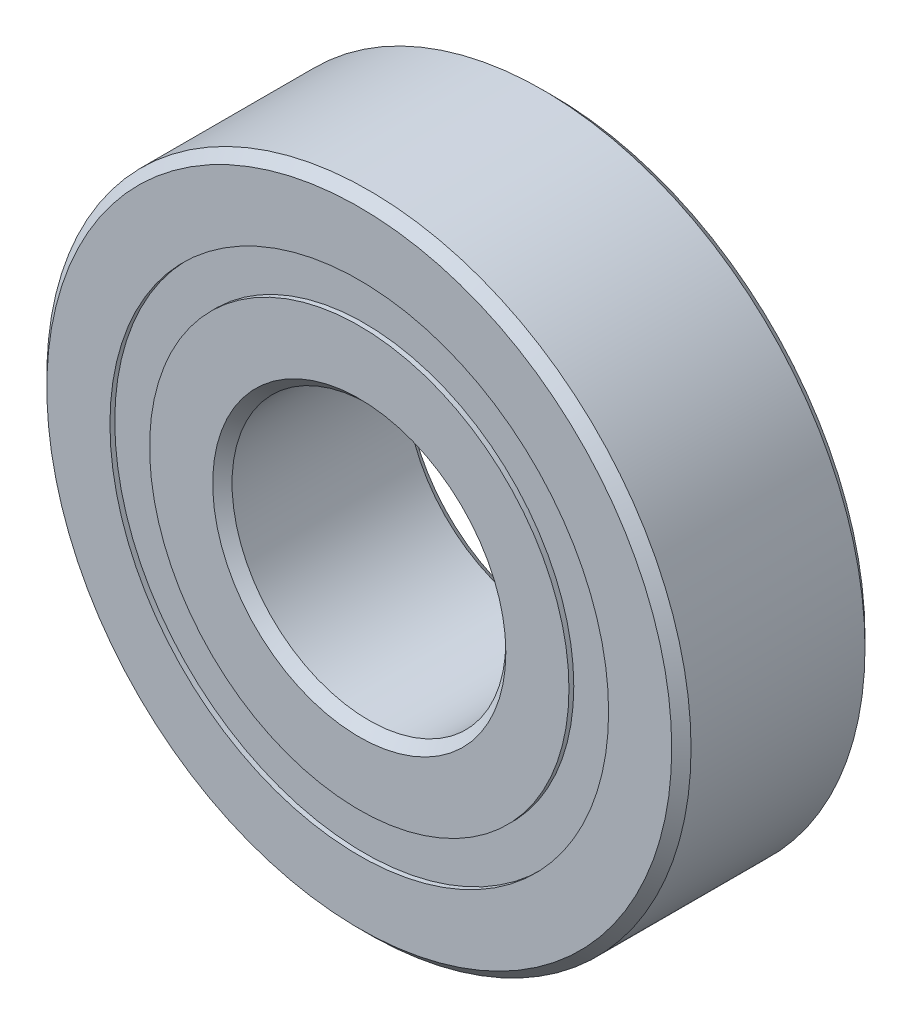
from build123d import *

# Parameters (mm, degrees)
CIRPATTERN1_COUNT = 14
SKETCH6_W         = 2.763011064
SKETCH6_H         = 2.461538462


with BuildPart() as part:
    # Sketch1 → Revolve1 (revolve)
    with BuildSketch(Plane(origin=(0, 0, 0), x_dir=(0, 0, -1), z_dir=(1, 0, 0))):
        with BuildLine():
            Line((5.4, 20), (-5.4, 20))
            Line((-5.4, 20), (-6, 19.4))
            Line((-6, 19.4), (-6, 15.480769231))
            Line((-6, 15.480769231), (-2.666666667, 15.480769231))
            ThreePointArc((-2.666666667, 15.480769231), (0, 17.186988936), (2.666666667, 15.480769231))
            Line((2.666666667, 15.480769231), (6, 15.480769231))
            Line((6, 15.480769231), (6, 19.4))
            Line((6, 19.4), (5.4, 20))
        make_face()
    revolve(axis=Axis((0, 0, 6), (0, 0, -1)))


with BuildPart() as body_2:
    # Sketch3 → Revolve3 (revolve)
    with BuildSketch(Plane(origin=(0, 0, 0), x_dir=(0, 0, -1), z_dir=(1, 0, 0))):
        with BuildLine():
            Line((-6, 13.019230769), (-2.666666667, 13.019230769))
            ThreePointArc((-2.666666667, 13.019230769), (0, 11.313011064), (2.666666667, 13.019230769))
            Line((2.666666667, 13.019230769), (6, 13.019230769))
            Line((6, 13.019230769), (6, 9.1))
            Line((6, 9.1), (5.4, 8.5))
            Line((5.4, 8.5), (-5.4, 8.5))
            Line((-5.4, 8.5), (-6, 9.1))
            Line((-6, 9.1), (-6, 13.019230769))
        make_face()
    revolve(axis=Axis((0, 0, 6), (0, 0, -1)))


with BuildPart() as body_3:
    # Sketch4 → Revolve4 (revolve)
    with BuildSketch(Plane(origin=(0, 0, 0), x_dir=(0, 0, -1), z_dir=(1, 0, 0))):
        with BuildLine():
            Line((-2.936988936, 14.25), (2.936988936, 14.25))
            ThreePointArc((2.936988936, 14.25), (0, 17.186988936), (-2.936988936, 14.25))
        make_face()
    revolve(axis=Axis((0, 14.25, 2.936988936), (0, 0, -1)))


with BuildPart() as cirpattern1_1:
    # CirPattern1: pattern copy
    add(body_3.part.rotate(Axis((0, 0, -6), (0, 0, 1)), 1 * 360 / CIRPATTERN1_COUNT))


with BuildPart() as cirpattern1_2:
    # CirPattern1: pattern copy
    add(body_3.part.rotate(Axis((0, 0, -6), (0, 0, 1)), 2 * 360 / CIRPATTERN1_COUNT))


with BuildPart() as cirpattern1_3:
    # CirPattern1: pattern copy
    add(body_3.part.rotate(Axis((0, 0, -6), (0, 0, 1)), 3 * 360 / CIRPATTERN1_COUNT))


with BuildPart() as cirpattern1_4:
    # CirPattern1: pattern copy
    add(body_3.part.rotate(Axis((0, 0, -6), (0, 0, 1)), 4 * 360 / CIRPATTERN1_COUNT))


with BuildPart() as cirpattern1_5:
    # CirPattern1: pattern copy
    add(body_3.part.rotate(Axis((0, 0, -6), (0, 0, 1)), 5 * 360 / CIRPATTERN1_COUNT))


with BuildPart() as cirpattern1_6:
    # CirPattern1: pattern copy
    add(body_3.part.rotate(Axis((0, 0, -6), (0, 0, 1)), 6 * 360 / CIRPATTERN1_COUNT))


with BuildPart() as cirpattern1_7:
    # CirPattern1: pattern copy
    add(body_3.part.rotate(Axis((0, 0, -6), (0, 0, 1)), 7 * 360 / CIRPATTERN1_COUNT))


with BuildPart() as cirpattern1_8:
    # CirPattern1: pattern copy
    add(body_3.part.rotate(Axis((0, 0, -6), (0, 0, 1)), 8 * 360 / CIRPATTERN1_COUNT))


with BuildPart() as cirpattern1_9:
    # CirPattern1: pattern copy
    add(body_3.part.rotate(Axis((0, 0, -6), (0, 0, 1)), 9 * 360 / CIRPATTERN1_COUNT))


with BuildPart() as cirpattern1_10:
    # CirPattern1: pattern copy
    add(body_3.part.rotate(Axis((0, 0, -6), (0, 0, 1)), 10 * 360 / CIRPATTERN1_COUNT))


with BuildPart() as cirpattern1_11:
    # CirPattern1: pattern copy
    add(body_3.part.rotate(Axis((0, 0, -6), (0, 0, 1)), 11 * 360 / CIRPATTERN1_COUNT))


with BuildPart() as cirpattern1_12:
    # CirPattern1: pattern copy
    add(body_3.part.rotate(Axis((0, 0, -6), (0, 0, 1)), 12 * 360 / CIRPATTERN1_COUNT))


with BuildPart() as cirpattern1_13:
    # CirPattern1: pattern copy
    add(body_3.part.rotate(Axis((0, 0, -6), (0, 0, 1)), 13 * 360 / CIRPATTERN1_COUNT))


with BuildPart() as body_17:
    # Sketch6 → Revolve5 (revolve)
    with BuildSketch(Plane(origin=(0, 0, 0), x_dir=(0, 0, -1), z_dir=(1, 0, 0))):
        with Locations((-4.318494468, 14.25)):
            Rectangle(SKETCH6_W, SKETCH6_H)
        with Locations((4.318494468, 14.25)):
            Rectangle(SKETCH6_W, SKETCH6_H)
    revolve(axis=Axis((0, 0, 6), (0, 0, -1)))


solid = Compound([part.part, body_2.part, body_3.part, cirpattern1_1.part, cirpattern1_2.part, cirpattern1_3.part, cirpattern1_4.part, cirpattern1_5.part, cirpattern1_6.part, cirpattern1_7.part, cirpattern1_8.part, cirpattern1_9.part, cirpattern1_10.part, cirpattern1_11.part, cirpattern1_12.part, cirpattern1_13.part, body_17.part])
